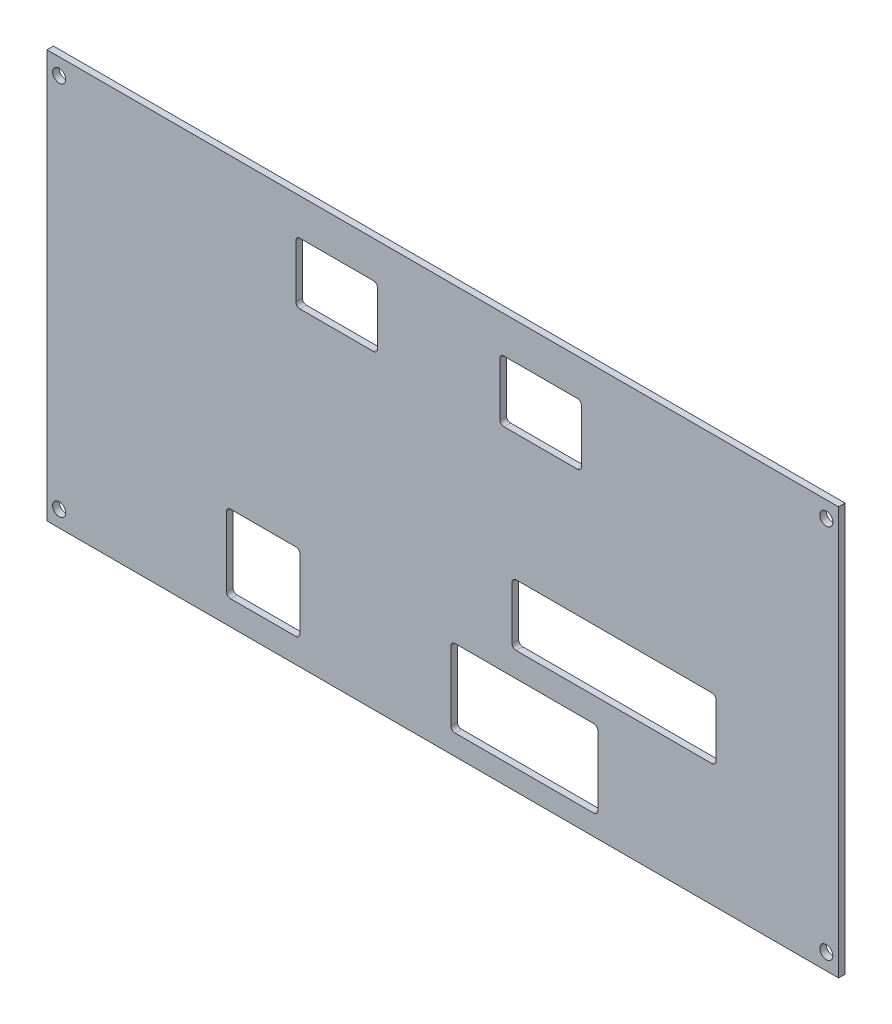
from build123d import *

# Parameters (mm, degrees)
ESQUISSE1_W             = 194
ESQUISSE1_H             = 100
BOSS_EXTRU_1_DEPTH      = 1.6
ESQUISSE2_R             = 1.6
ENL_V_MAT_EXTRU_1_DEPTH = 1.6


with BuildPart() as part:
    # Esquisse1 → Boss.-Extru.1 (new body)
    with BuildSketch(Plane.XY):
        with Locations((97, 50)):
            Rectangle(ESQUISSE1_W, ESQUISSE1_H)
    extrude(amount=BOSS_EXTRU_1_DEPTH)

    # Esquisse2 → Enlèv. mat.-Extru.1 (cut)
    with BuildSketch(Plane.XY.offset(1.6)):
        with Locations((3, 96)):
            Circle(ESQUISSE2_R)
        with Locations((191, 96)):
            Circle(ESQUISSE2_R)
        with Locations((191, 4)):
            Circle(ESQUISSE2_R)
        with Locations((3, 4)):
            Circle(ESQUISSE2_R)
        with BuildLine():
            Line((45, 25), (61, 25))
            ThreePointArc((61, 25), (61.707106781, 24.707106781), (62, 24))
            Line((62, 24), (62, 7))
            ThreePointArc((62, 7), (61.707106781, 6.292893219), (61, 6))
            Line((61, 6), (45, 6))
            ThreePointArc((45, 6), (44.292893219, 6.292893219), (44, 7))
            Line((44, 7), (44, 24))
            ThreePointArc((44, 24), (44.292893219, 24.707106781), (45, 25))
        make_face()
        with BuildLine():
            Line((62, 91), (80, 91))
            ThreePointArc((80, 91), (80.707106781, 90.707106781), (81, 90))
            Line((81, 90), (81, 77))
            ThreePointArc((81, 77), (80.707106781, 76.292893219), (80, 76))
            Line((80, 76), (62, 76))
            ThreePointArc((62, 76), (61.292893219, 76.292893219), (61, 77))
            Line((61, 77), (61, 90))
            ThreePointArc((61, 90), (61.292893219, 90.707106781), (62, 91))
        make_face()
        with BuildLine():
            Line((112, 91), (130, 91))
            ThreePointArc((130, 91), (130.707106781, 90.707106781), (131, 90))
            Line((131, 90), (131, 77))
            ThreePointArc((131, 77), (130.707106781, 76.292893219), (130, 76))
            Line((130, 76), (112, 76))
            ThreePointArc((112, 76), (111.292893219, 76.292893219), (111, 77))
            Line((111, 77), (111, 90))
            ThreePointArc((111, 90), (111.292893219, 90.707106781), (112, 91))
        make_face()
        with BuildLine():
            Line((115, 45), (163, 45))
            ThreePointArc((163, 45), (163.707106781, 44.707106781), (164, 44))
            Line((164, 44), (164, 31))
            ThreePointArc((164, 31), (163.707106781, 30.292893219), (163, 30))
            Line((163, 30), (115, 30))
            ThreePointArc((115, 30), (114.292893219, 30.292893219), (114, 31))
            Line((114, 31), (114, 44))
            ThreePointArc((114, 44), (114.292893219, 44.707106781), (115, 45))
        make_face()
        with BuildLine():
            Line((100, 24), (134, 24))
            ThreePointArc((134, 24), (134.707106781, 23.707106781), (135, 23))
            Line((135, 23), (135, 6))
            ThreePointArc((135, 6), (134.707106781, 5.292893219), (134, 5))
            Line((134, 5), (100, 5))
            ThreePointArc((100, 5), (99.292893219, 5.292893219), (99, 6))
            Line((99, 6), (99, 23))
            ThreePointArc((99, 23), (99.292893219, 23.707106781), (100, 24))
        make_face()
    extrude(amount=-ENL_V_MAT_EXTRU_1_DEPTH, mode=Mode.SUBTRACT)


solid = part.part
